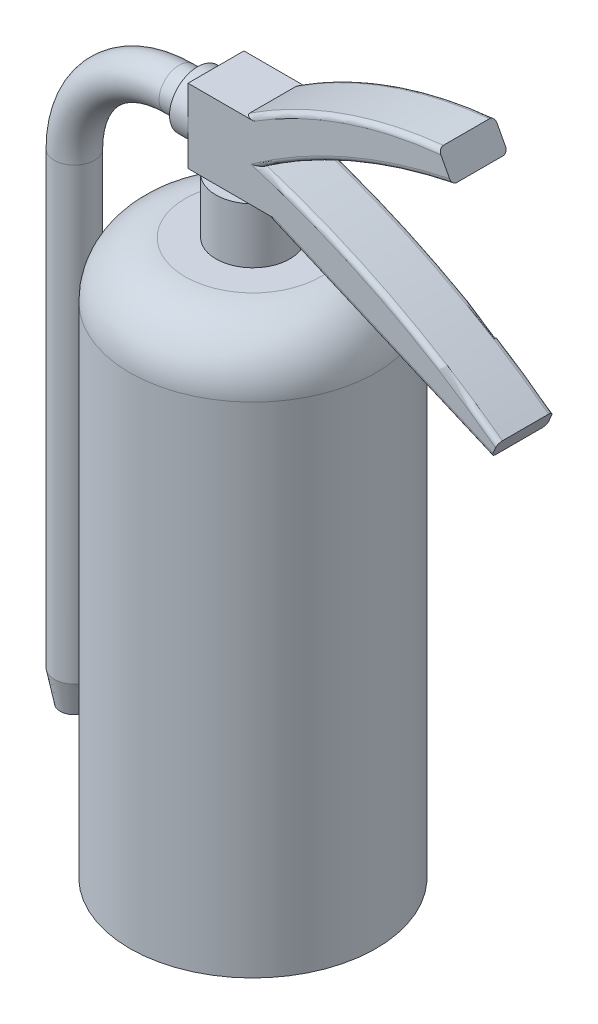
from build123d import *

# Parameters (mm, degrees)
CROQUIS1_R              = 200
SALIENTE_EXTRUIR1_DEPTH = 900
REDONDEO1_R             = 90
CROQUIS2_R              = 60
SALIENTE_EXTRUIR2_DEPTH = 90
CROQUIS3_W              = 120
CROQUIS3_H              = 90.836251912
SALIENTE_EXTRUIR3_DEPTH = 60
SALIENTE_EXTRUIR4_DEPTH = 90.836252
CROQUIS5_W              = 120
CROQUIS5_H              = 90.836251912
SALIENTE_EXTRUIR5_DEPTH = 60
SALIENTE_EXTRUIR6_DEPTH = 90.836252
REDONDEO2_R             = 8
CROQUIS8_R              = 45.418125956
SALIENTE_EXTRUIR7_DEPTH = 30
CROQUIS9_R              = 32.5
CROQUIS10_R             = 32.5
SALIENTE_EXTRUIR8_DEPTH = 50
SALIENTE_EXTRUIR8_TAPER = 11


with BuildPart() as part:
    # Croquis1 → Saliente-Extruir1 (new body)
    with BuildSketch(Plane(origin=(0, 0, 0), x_dir=(1, 0, 0), z_dir=(0, 1, 0))):
        Circle(CROQUIS1_R)
    extrude(amount=SALIENTE_EXTRUIR1_DEPTH)

    # Redondeo1
    redondeo1_edges = [part.edges().sort_by_distance(p)[0] for p in [
        (-200, 900, 0),
    ]]
    fillet(redondeo1_edges, radius=REDONDEO1_R)

    # Croquis2 → Saliente-Extruir2 (add)
    with BuildSketch(Plane(origin=(0, 900, 0), x_dir=(1, 0, 0), z_dir=(0, 1, 0))):
        Circle(CROQUIS2_R)
    extrude(amount=SALIENTE_EXTRUIR2_DEPTH)

    # Croquis3 → Saliente-Extruir3 (add)
    with BuildSketch(Plane(origin=(0, 990, 0), x_dir=(1, 0, 0), z_dir=(0, 1, 0))):
        Rectangle(CROQUIS3_W, CROQUIS3_H)
    extrude(amount=SALIENTE_EXTRUIR3_DEPTH)

    # Croquis4 → Saliente-Extruir4 (add)
    with BuildSketch(Plane.XY.offset(45.418125956)):
        with BuildLine():
            Line((60, 990), (432.304083803, 829.898605595))
            Line((432.304083803, 829.898605595), (442.878538819, 854.488727381))
            ThreePointArc((442.878538819, 854.488727381), (259.713592606, 968.448343813), (60, 1050))
            Line((60, 1050), (60, 990))
        make_face()
    extrude(amount=-SALIENTE_EXTRUIR4_DEPTH)

    # Croquis5 → Saliente-Extruir5 (add)
    with BuildSketch(Plane(origin=(0, 1050, 0), x_dir=(1, 0, 0), z_dir=(0, 1, 0))):
        Rectangle(CROQUIS5_W, CROQUIS5_H)
    extrude(amount=SALIENTE_EXTRUIR5_DEPTH)

    # Croquis6 → Saliente-Extruir6 (add)
    with BuildSketch(Plane.XY.offset(45.418125956)):
        with BuildLine():
            Line((346.814814122, 1222.018811659), (368.82653308, 1180.746838612))
            ThreePointArc((368.82653308, 1180.746838612), (207.813070235, 1130.963209195), (60, 1050))
            Line((60, 1050), (60, 1110))
            Line((60, 1110), (32.230664011, 1110))
            ThreePointArc((32.230664011, 1110), (182.778174474, 1184.950270214), (346.814814122, 1222.018811659))
        make_face()
    extrude(amount=-SALIENTE_EXTRUIR6_DEPTH)

    # Redondeo2
    redondeo2_edges = [part.edges().sort_by_distance(p)[0] for p in [
        (246.152041901, 909.949302798, 45.418125956),
        (259.713592606, 968.448343813, 45.418125956),
        (259.713592606, 968.448343813, -45.418126044),
        (246.152041901, 909.949302798, -45.418126044),
        (207.813070235, 1130.963209195, 45.418125956),
        (182.778174474, 1184.950270214, 45.418125956),
        (207.813070235, 1130.963209195, -45.418126044),
        (182.778174474, 1184.950270214, -45.418126044),
    ]]
    fillet(redondeo2_edges, radius=REDONDEO2_R)

    # Croquis8 → Saliente-Extruir7 (add)
    with BuildSketch(Plane.ZY.offset(60)):
        with Locations((0, 1050)):
            Circle(CROQUIS8_R)
    extrude(amount=SALIENTE_EXTRUIR7_DEPTH)

    # Barrer1: sweep along a curve in space
    with BuildLine() as barrer1_path:
        Line((-90, 1050, 0), (-120, 1050, 0))
        ThreePointArc((-120, 1050, 0), (-240.208152802, 1000.208152802, 0), (-290, 880, 0))
        Line((-290, 880, 0), (-290, 150, 0))
    # Croquis9 → Barrer1 (sweep)
    with BuildSketch(Plane.ZY.offset(90)):
        with Locations((0, 1050)):
            Circle(CROQUIS9_R)
    sweep(path=barrer1_path.line)

    # Croquis10 → Saliente-Extruir8 (add)
    with BuildSketch(Plane.XZ.offset(-150)):
        with Locations((-290, 0)):
            Circle(CROQUIS10_R)
    extrude(amount=SALIENTE_EXTRUIR8_DEPTH, taper=SALIENTE_EXTRUIR8_TAPER)


solid = part.part
